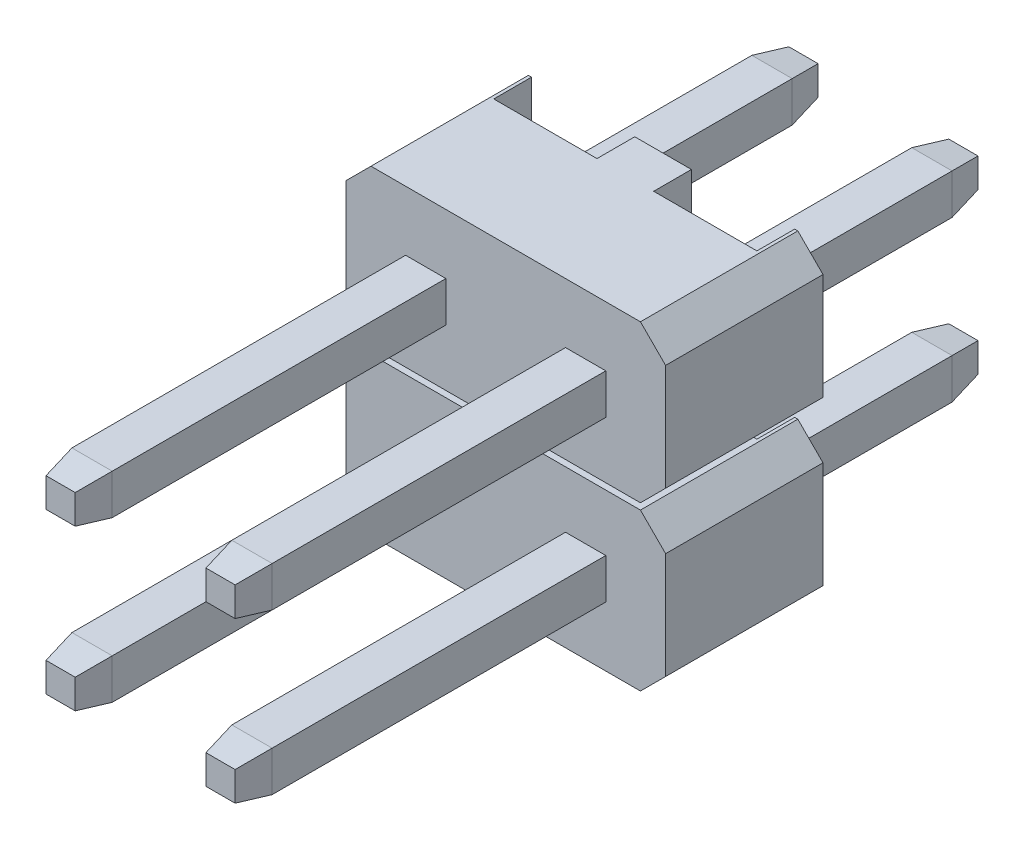
from build123d import *

# Parameters (mm, degrees)
SKETCH1_W             = 0.64
SKETCH1_H             = 0.64
BOSS_EXTRUDE1_DEPTH   = 5.3
BOSS_EXTRUDE1_2_DEPTH = 5.3
BOSS_EXTRUDE1_3_DEPTH = 5.3
BOSS_EXTRUDE1_4_DEPTH = 5.3
SKETCH2_W             = 0.64
SKETCH2_H             = 0.64
BOSS_EXTRUDE2_DEPTH   = 0.5
BOSS_EXTRUDE2_TAPER   = 10
BOSS_EXTRUDE3_DEPTH   = 2.5
SKETCH5_W             = 1.64
SKETCH5_H             = 5.08
CUT_EXTRUDE1_DEPTH    = 0.6
SKETCH6_W             = 5.08
SKETCH6_H             = 0.1
CUT_EXTRUDE2_DEPTH    = 3.5
CUT_EXTRUDE3_DEPTH    = 3.5
SKETCH8_W             = 0.64
SKETCH8_H             = 0.64
BOSS_EXTRUDE4_DEPTH   = 3.6
BOSS_EXTRUDE4_2_DEPTH = 3.6
BOSS_EXTRUDE4_3_DEPTH = 3.6
BOSS_EXTRUDE4_4_DEPTH = 3.6
SKETCH9_W             = 0.64
SKETCH9_H             = 0.64
BOSS_EXTRUDE5_DEPTH   = 0.5
BOSS_EXTRUDE5_TAPER   = 10


with BuildPart() as part:
    # Sketch1 → Boss-Extrude1 (new body)
    with BuildSketch(Plane.XY):
        with Locations((-1.27, 1.27)):
            Rectangle(SKETCH1_W, SKETCH1_H)
    extrude(amount=BOSS_EXTRUDE1_DEPTH)



with BuildPart() as body_2:
    # Sketch1 → Boss-Extrude1 2 (new body)
    with BuildSketch(Plane.XY):
        with Locations((-1.27, -1.27)):
            Rectangle(SKETCH1_W, SKETCH1_H)
    extrude(amount=BOSS_EXTRUDE1_2_DEPTH)


with BuildPart() as body_3:
    # Sketch1 → Boss-Extrude1 3 (new body)
    with BuildSketch(Plane.XY):
        with Locations((1.27, 1.27)):
            Rectangle(SKETCH1_W, SKETCH1_H)
    extrude(amount=BOSS_EXTRUDE1_3_DEPTH)


with BuildPart() as body_4:
    # Sketch1 → Boss-Extrude1 4 (new body)
    with BuildSketch(Plane.XY):
        with Locations((1.27, -1.27)):
            Rectangle(SKETCH1_W, SKETCH1_H)
    extrude(amount=BOSS_EXTRUDE1_4_DEPTH)


with BuildPart() as part_1:
    add(part.part)

    add(body_2.part)  # Boss-Extrude2 merges body 2

    add(body_3.part)  # Boss-Extrude2 merges body 3

    add(body_4.part)  # Boss-Extrude2 merges body 4
    # Sketch2 → Boss-Extrude2 (add)
    with BuildSketch(Plane.XY.offset(5.3)):
        with Locations((-1.27, -1.27)):
            Rectangle(SKETCH2_W, SKETCH2_H)
        with Locations((-1.27, 1.27)):
            Rectangle(SKETCH2_W, SKETCH2_H)
        with Locations((1.27, -1.27)):
            Rectangle(SKETCH2_W, SKETCH2_H)
        with Locations((1.27, 1.27)):
            Rectangle(SKETCH2_W, SKETCH2_H)
    extrude(amount=BOSS_EXTRUDE2_DEPTH, taper=BOSS_EXTRUDE2_TAPER)


with BuildPart() as body_2_2:
    # Sketch3 → Boss-Extrude3 (new body)
    with BuildSketch(Plane.XY):
        Polygon((-2.14, 2.54), (2.14, 2.54), (2.54, 2.14), (2.54, -2.14), (2.14, -2.54), (-2.14, -2.54), (-2.54, -2.14), (-2.54, 2.14), align=None)
    extrude(amount=-BOSS_EXTRUDE3_DEPTH)

    # Sketch5 → Cut-Extrude1 (cut)
    with BuildSketch(Plane(origin=(0, 0, -2.5), x_dir=(-1, 0, 0), z_dir=(0, 0, -1))):
        with Locations((-1.27, 0)):
            Rectangle(SKETCH5_W, SKETCH5_H)
        with Locations((1.27, 0)):
            Rectangle(SKETCH5_W, SKETCH5_H)
    extrude(amount=-CUT_EXTRUDE1_DEPTH, mode=Mode.SUBTRACT)

    # Sketch6 → Cut-Extrude2 (cut, through all)
    with BuildSketch(Plane.XY):
        Rectangle(SKETCH6_W, SKETCH6_H)
    extrude(amount=-CUT_EXTRUDE2_DEPTH, mode=Mode.SUBTRACT)

    # Sketch7 → Cut-Extrude3 (cut, through all)
    with BuildSketch(Plane.XY):
        Polygon((2.54, 0.45), (2.14, 0.05), (2.54, 0.05), align=None)
        Polygon((2.54, -0.05), (2.14, -0.05), (2.54, -0.45), align=None)
        Polygon((-2.54, -0.45), (-2.54, -0.05), (-2.14, -0.05), align=None)
        Polygon((-2.54, 0.05), (-2.54, 0.45), (-2.14, 0.05), align=None)
    extrude(amount=-CUT_EXTRUDE3_DEPTH, mode=Mode.SUBTRACT)


with BuildPart() as body_3_2:
    # Sketch8 → Boss-Extrude4 (new body)
    with BuildSketch(Plane(origin=(0, 0, -1.9), x_dir=(-1, 0, 0), z_dir=(0, 0, -1))):
        with Locations((1.27, -1.27)):
            Rectangle(SKETCH8_W, SKETCH8_H)
    extrude(amount=BOSS_EXTRUDE4_DEPTH)



with BuildPart() as body_4_2:
    # Sketch8 → Boss-Extrude4 2 (new body)
    with BuildSketch(Plane(origin=(0, 0, -1.9), x_dir=(-1, 0, 0), z_dir=(0, 0, -1))):
        with Locations((1.27, 1.27)):
            Rectangle(SKETCH8_W, SKETCH8_H)
    extrude(amount=BOSS_EXTRUDE4_2_DEPTH)


with BuildPart() as body_5:
    # Sketch8 → Boss-Extrude4 3 (new body)
    with BuildSketch(Plane(origin=(0, 0, -1.9), x_dir=(-1, 0, 0), z_dir=(0, 0, -1))):
        with Locations((-1.27, 1.27)):
            Rectangle(SKETCH8_W, SKETCH8_H)
    extrude(amount=BOSS_EXTRUDE4_3_DEPTH)


with BuildPart() as body_6:
    # Sketch8 → Boss-Extrude4 4 (new body)
    with BuildSketch(Plane(origin=(0, 0, -1.9), x_dir=(-1, 0, 0), z_dir=(0, 0, -1))):
        with Locations((-1.27, -1.27)):
            Rectangle(SKETCH8_W, SKETCH8_H)
    extrude(amount=BOSS_EXTRUDE4_4_DEPTH)


with BuildPart() as body_3_2_1:
    add(body_3_2.part)

    add(body_4_2.part)  # Boss-Extrude5 merges body 4 2

    add(body_5.part)  # Boss-Extrude5 merges body 5

    add(body_6.part)  # Boss-Extrude5 merges body 6
    # Sketch9 → Boss-Extrude5 (add)
    with BuildSketch(Plane(origin=(0, 0, -5.5), x_dir=(-1, 0, 0), z_dir=(0, 0, -1))):
        with Locations((1.27, 1.27)):
            Rectangle(SKETCH9_W, SKETCH9_H)
        with Locations((1.27, -1.27)):
            Rectangle(SKETCH9_W, SKETCH9_H)
        with Locations((-1.27, -1.27)):
            Rectangle(SKETCH9_W, SKETCH9_H)
        with Locations((-1.27, 1.27)):
            Rectangle(SKETCH9_W, SKETCH9_H)
    extrude(amount=BOSS_EXTRUDE5_DEPTH, taper=BOSS_EXTRUDE5_TAPER)


solid = Compound([part_1.part, body_2_2.part, body_3_2_1.part])
